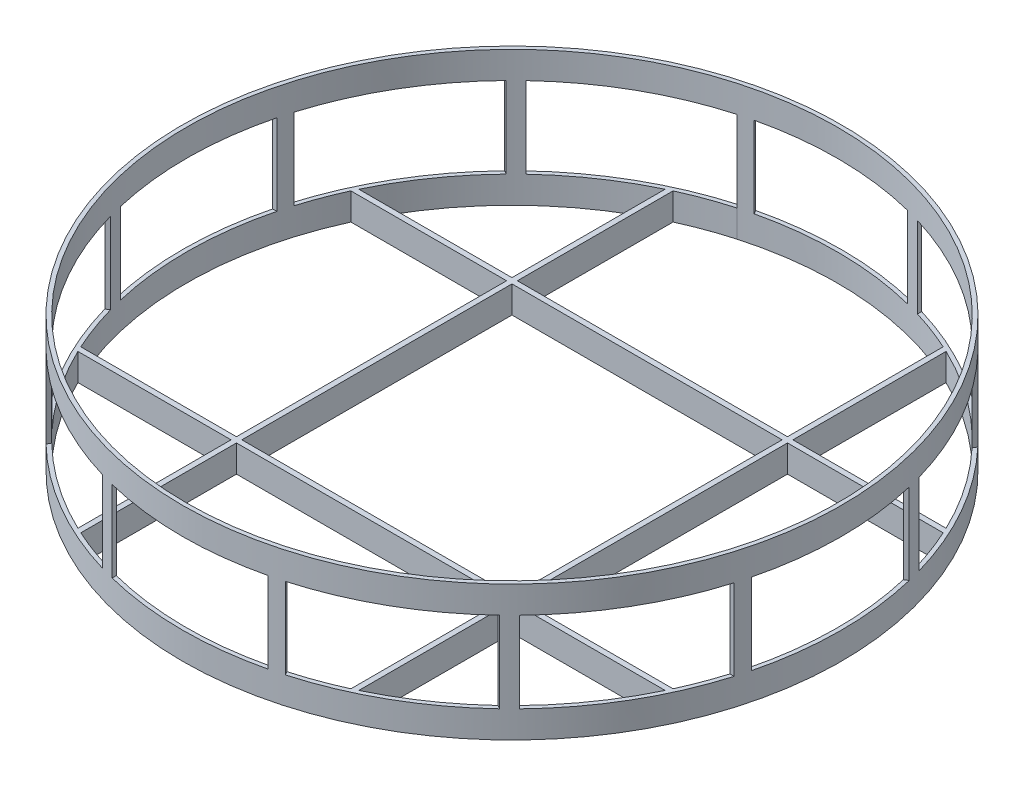
from build123d import *

# Parameters (mm, degrees)
SKETCH1_R           = 122
SKETCH1_R_2         = 120.5
BOSS_EXTRUDE1_DEPTH = 10
BOSS_EXTRUDE2_DEPTH = 30
CIRPATTERN1_COUNT   = 12
SKETCH4_R           = 122
SKETCH4_R_2         = 120.5
BOSS_EXTRUDE3_DEPTH = 10
SKETCH6_W           = 2
SKETCH6_H           = 219.273801444
BOSS_EXTRUDE4_DEPTH = 10
CIRPATTERN2_COUNT   = 4


with BuildPart() as part:
    # Sketch1 → Boss-Extrude1 (new body)
    with BuildSketch(Plane(origin=(0, 0, 0), x_dir=(1, 0, 0), z_dir=(0, 1, 0))):
        Circle(SKETCH1_R)
        Circle(SKETCH1_R_2, mode=Mode.SUBTRACT)
    extrude(amount=BOSS_EXTRUDE1_DEPTH)

    # Sketch3 → Boss-Extrude2 (add)
    with BuildSketch(Plane(origin=(0, 10, 0), x_dir=(1, 0, 0), z_dir=(0, 1, 0))):
        with BuildLine():
            Line((34.717842259, 115.390300411), (34.717842259, 116.955852478))
            ThreePointArc((34.717842259, 116.955852478), (32.225116431, 117.66708066), (29.717842259, 118.325186885))
            Line((29.717842259, 118.325186885), (29.717842259, 116.777993866))
            ThreePointArc((29.717842259, 116.777993866), (32.22531277, 116.111064145), (34.717842259, 115.390300411))
        make_face()
    boss_extrude2 = extrude(amount=BOSS_EXTRUDE2_DEPTH)

    # CirPattern1: Boss-Extrude2 ×12 about axis
    cirpattern1_axis = Axis((0, 0, 0), (0, 1, 0))
    for i in range(1, CIRPATTERN1_COUNT):
        add(boss_extrude2.rotate(cirpattern1_axis, i * 360 / CIRPATTERN1_COUNT))

    # Sketch4 → Boss-Extrude3 (add)
    with BuildSketch(Plane(origin=(0, 40, 0), x_dir=(1, 0, 0), z_dir=(0, 1, 0))):
        Circle(SKETCH4_R)
        Circle(SKETCH4_R_2, mode=Mode.SUBTRACT)
    extrude(amount=BOSS_EXTRUDE3_DEPTH)

    # Sketch6 → Boss-Extrude4 (add)
    with BuildSketch(Plane(origin=(0, 0, 0), x_dir=(1, 0, 0), z_dir=(0, 1, 0))):
        with Locations((-51, 0)):
            Rectangle(SKETCH6_W, SKETCH6_H)
    boss_extrude4 = extrude(amount=BOSS_EXTRUDE4_DEPTH)

    # CirPattern2: Boss-Extrude4 ×4 about axis
    cirpattern2_axis = Axis((0, 0, 0), (0, 1, 0))
    for i in range(1, CIRPATTERN2_COUNT):
        add(boss_extrude4.rotate(cirpattern2_axis, i * 360 / CIRPATTERN2_COUNT))


solid = part.part
